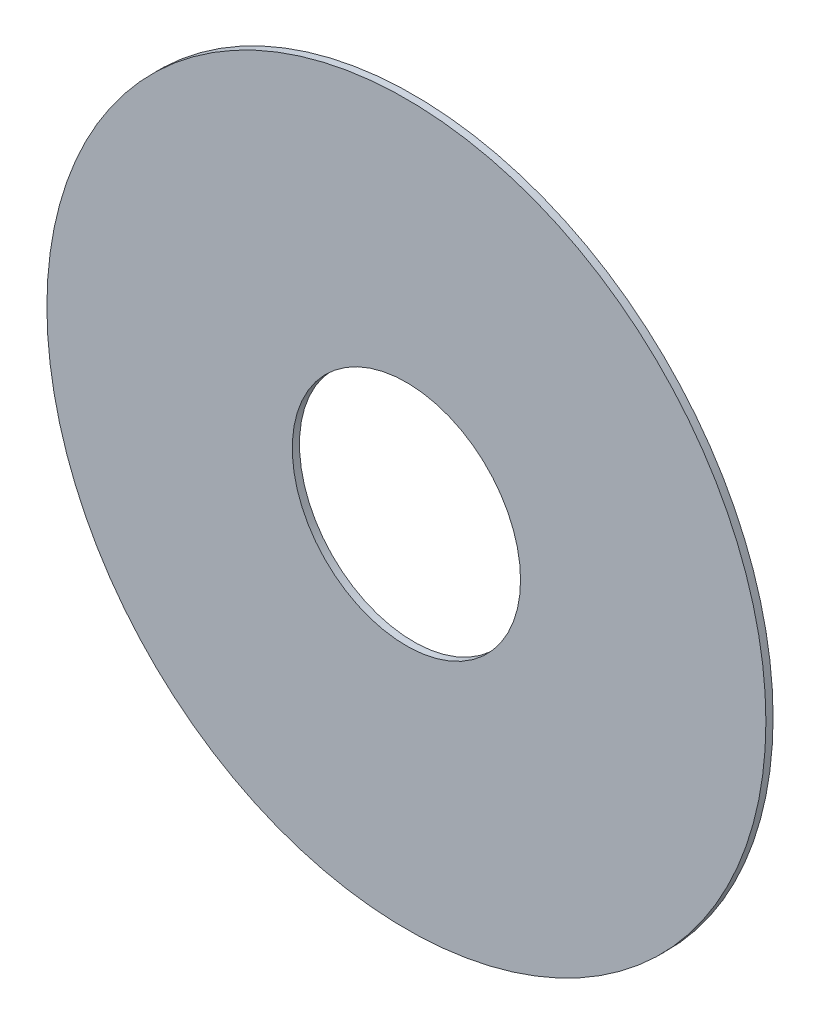
from build123d import *

# Parameters (mm, degrees)
SKETCH1_R           = 100
SKETCH1_R_2         = 31.75
BOSS_EXTRUDE1_DEPTH = 2


with BuildPart() as part:
    # Sketch1 → Boss-Extrude1 (new body)
    with BuildSketch(Plane.XY):
        Circle(SKETCH1_R)
        Circle(SKETCH1_R_2, mode=Mode.SUBTRACT)
    extrude(amount=BOSS_EXTRUDE1_DEPTH)


solid = part.part
